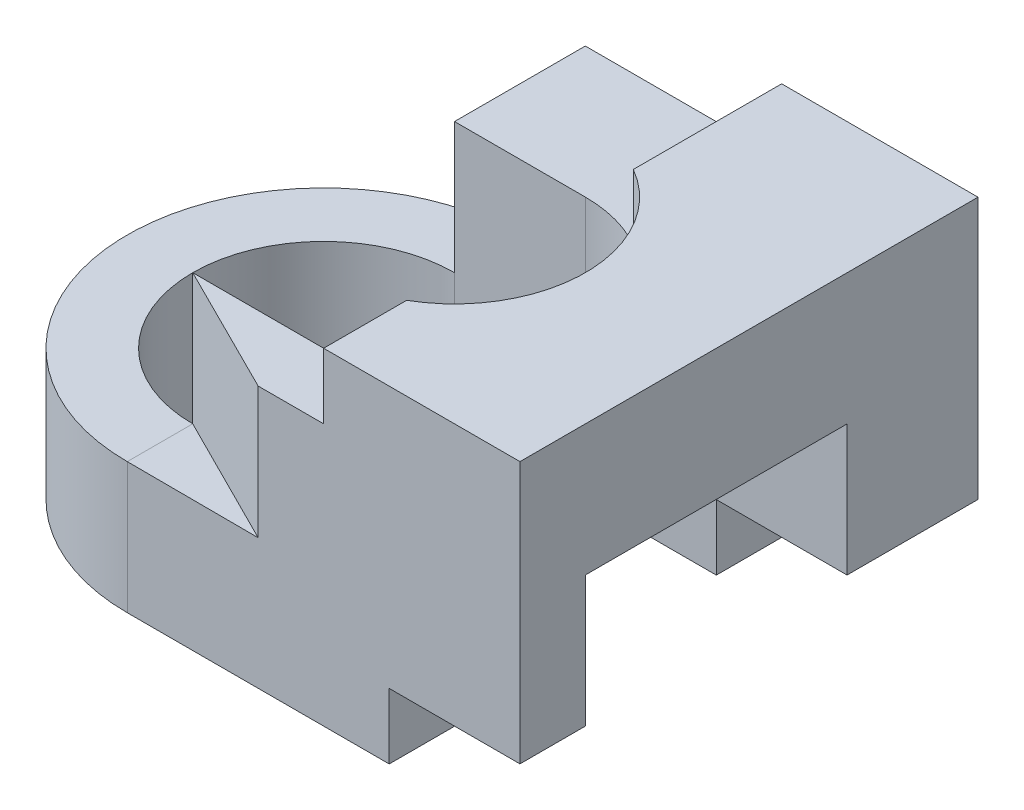
from build123d import *

# Parameters (mm, degrees)
BOSS_EXTRUDE1_DEPTH = 5
CUT_EXTRUDE10_DEPTH = 7
SKETCH4_W           = 1.997648265
SKETCH4_H           = 6.998360209
CUT_EXTRUDE11_DEPTH = 1
SKETCH5_W           = 6
SKETCH5_H           = 3.997736752
CUT_EXTRUDE12_DEPTH = 3
CUT_EXTRUDE13_DEPTH = 3


with BuildPart() as part:
    # Sketch2 → Boss-Extrude1 (new body)
    with BuildSketch(Plane(origin=(0, 0, 0), x_dir=(1, 0, 0), z_dir=(0, 1, 0))):
        with BuildLine():
            Line((0, 3), (0, 3.998360209))
            Line((0, 3.998360209), (6, 3.998360209))
            Line((6, 3.998360209), (6, -3))
            Line((6, -3), (0, -3))
            ThreePointArc((0, -3), (-3, 0), (0, 3))
        make_face()
        with BuildLine():
            Line((0, 2), (2, 2))
            ThreePointArc((2, 2), (4, 0), (2, -2))
            Line((2, -2), (0, -2))
            ThreePointArc((0, -2), (-2, 0), (0, 2))
        make_face(mode=Mode.SUBTRACT)
    extrude(amount=BOSS_EXTRUDE1_DEPTH)

    # Sketch3 → Cut-Extrude10 (cut)
    with BuildSketch(Plane.XY.offset(3)):
        Polygon((3, 5), (-3, 5), (-3, 4), (-3, 2), (0, 2), (0, 4), (3, 4), align=None)
    extrude(amount=-CUT_EXTRUDE10_DEPTH, mode=Mode.SUBTRACT)

    # Sketch4 → Cut-Extrude11 (cut)
    with BuildSketch(Plane.XZ):
        with Locations((5.001175868, -0.499180105)):
            Rectangle(SKETCH4_W, SKETCH4_H)
    extrude(amount=-CUT_EXTRUDE11_DEPTH, mode=Mode.SUBTRACT)

    # Sketch5 → Cut-Extrude12 (cut)
    with BuildSketch(Plane.XZ):
        with Locations((3, 0.001131624)):
            Rectangle(SKETCH5_W, SKETCH5_H)
    extrude(amount=-CUT_EXTRUDE12_DEPTH, mode=Mode.SUBTRACT)

    # 3DSketch1 → Cut-Extrude13 (cut, along a direction that is not the sketch's normal)
    with BuildSketch(Plane(origin=(0, 2, 2), x_dir=(0.6666666666666625, 0.66666666666667, 0.3333333333333349), z_dir=(0.4472135954999618, 0, -0.894427190999914))):
        Polygon((0, 0), (1.333333333, -1.490711985), (3, 0), (1.661678745, 1.496288651), align=None)
    extrude(amount=-CUT_EXTRUDE13_DEPTH, dir=(0, 0, -1), mode=Mode.SUBTRACT)


solid = part.part
